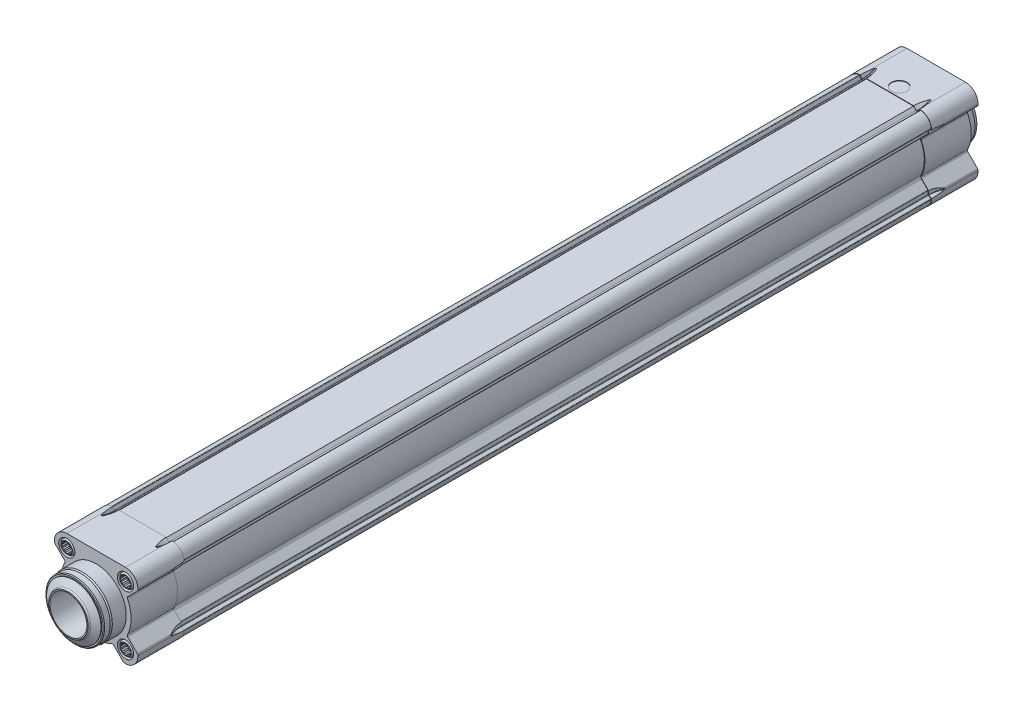
from build123d import *

# Parameters (mm, degrees)
BOSS_EXTRUDE1_DEPTH  = 30
SKETCH6_W            = 484
SKETCH6_H            = 5
BOSS_EXTRUDE2_START  = -30
BOSS_EXTRUDE2_DEPTH  = 30
BOSS_EXTRUDE3_DEPTH  = 484
SKETCH14_W           = 5
SKETCH14_H           = 0.3
SKETCH15_W           = 21.1
SKETCH15_H           = 5.25
LPATTERN1_COUNT      = 2
LPATTERN1_PITCH      = 38
LPATTERN1_COUNT_DIR2 = 2
LPATTERN1_PITCH_DIR2 = 38
LPATTERN2_COUNT      = 2
LPATTERN2_PITCH      = 38
LPATTERN2_COUNT_DIR2 = 2
LPATTERN2_PITCH_DIR2 = 38
CUT_EXTRUDE1_DEPTH   = 4
LPATTERN3_COUNT      = 2
LPATTERN3_PITCH      = 38
LPATTERN3_COUNT_DIR2 = 2
LPATTERN3_PITCH_DIR2 = 38
LPATTERN4_COUNT      = 2
LPATTERN4_PITCH      = 38
LPATTERN4_COUNT_DIR2 = 2
LPATTERN4_PITCH_DIR2 = 38
SKETCH25_W           = 21.1
SKETCH25_H           = 5.25
LPATTERN5_COUNT      = 2
LPATTERN5_PITCH      = 38
LPATTERN5_COUNT_DIR2 = 2
LPATTERN5_PITCH_DIR2 = 38
LPATTERN6_COUNT      = 2
LPATTERN6_PITCH      = 38
LPATTERN6_COUNT_DIR2 = 2
LPATTERN6_PITCH_DIR2 = 38
LPATTERN7_COUNT      = 2
LPATTERN7_PITCH      = 38
LPATTERN7_COUNT_DIR2 = 2
LPATTERN7_PITCH_DIR2 = 38
CUT_EXTRUDE2_DEPTH   = 4
LPATTERN8_COUNT      = 2
LPATTERN8_PITCH      = 38
LPATTERN8_COUNT_DIR2 = 2
LPATTERN8_PITCH_DIR2 = 38


with BuildPart() as part:
    # Sketch1 → Boss-Extrude1 (new body)
    with BuildSketch(Plane.XY.offset(-30)):
        with BuildLine():
            Line((-26.707106781, 17.514718626), (-20.456088466, 11.26370031))
            ThreePointArc((-20.456088466, 11.26370031), (-20.176183637, 10.717242468), (-20.268345554, 10.110225938))
            ThreePointArc((-20.268345554, 10.110225938), (-22.65, 0), (-20.268345554, -10.110225938))
            ThreePointArc((-20.268345554, -10.110225938), (-20.176183637, -10.717242468), (-20.456088466, -11.26370031))
            Line((-20.456088466, -11.26370031), (-26.707106781, -17.514718626))
            ThreePointArc((-26.707106781, -17.514718626), (-26.923879533, -17.839141975), (-27, -18.221825407))
            Line((-27, -18.221825407), (-27, -19))
            ThreePointArc((-27, -19), (-24.656854249, -24.656854249), (-19, -27))
            Line((-19, -27), (-18.221825407, -27))
            ThreePointArc((-18.221825407, -27), (-17.839141975, -26.923879533), (-17.514718626, -26.707106781))
            Line((-17.514718626, -26.707106781), (-11.26370031, -20.456088466))
            ThreePointArc((-11.26370031, -20.456088466), (-10.717242468, -20.176183637), (-10.110225938, -20.268345554))
            ThreePointArc((-10.110225938, -20.268345554), (0, -22.65), (10.110225938, -20.268345554))
            ThreePointArc((10.110225938, -20.268345554), (10.717242468, -20.176183637), (11.26370031, -20.456088466))
            Line((11.26370031, -20.456088466), (17.514718626, -26.707106781))
            ThreePointArc((17.514718626, -26.707106781), (17.839141975, -26.923879533), (18.221825407, -27))
            Line((18.221825407, -27), (19, -27))
            ThreePointArc((19, -27), (24.656854249, -24.656854249), (27, -19))
            Line((27, -19), (27, -18.221825407))
            ThreePointArc((27, -18.221825407), (26.923879533, -17.839141975), (26.707106781, -17.514718626))
            Line((26.707106781, -17.514718626), (20.456088466, -11.26370031))
            ThreePointArc((20.456088466, -11.26370031), (20.176183637, -10.717242468), (20.268345554, -10.110225938))
            ThreePointArc((20.268345554, -10.110225938), (22.65, 0), (20.268345554, 10.110225938))
            ThreePointArc((20.268345554, 10.110225938), (20.176183637, 10.717242468), (20.456088466, 11.26370031))
            Line((20.456088466, 11.26370031), (26.707106781, 17.514718626))
            ThreePointArc((26.707106781, 17.514718626), (26.923879533, 17.839141975), (27, 18.221825407))
            Line((27, 18.221825407), (27, 19))
            ThreePointArc((27, 19), (24.656854249, 24.656854249), (19, 27))
            Line((19, 27), (-19, 27))
            ThreePointArc((-19, 27), (-24.656854249, 24.656854249), (-27, 19))
            Line((-27, 19), (-27, 18.221825407))
            ThreePointArc((-27, 18.221825407), (-26.923879533, 17.839141975), (-26.707106781, 17.514718626))
        make_face()
    extrude(amount=BOSS_EXTRUDE1_DEPTH)

    # Sketch2 → Cut-Revolve1 (revolve, cut)
    with BuildSketch(Plane.XY.offset(-30)):
        with BuildLine():
            Line((-19.3, 33.75), (-19.3, 27))
            Line((-19.3, 27), (-18.203034489, 25.1))
            ThreePointArc((-18.203034489, 25.1), (-18.129829408, 25.026794919), (-18.029829408, 25))
            Line((-18.029829408, 25), (-17.328142174, 25))
            ThreePointArc((-17.328142174, 25), (-17.251605488, 25.015224093), (-17.186720818, 25.058578644))
            Line((-17.186720818, 25.058578644), (-15.245299462, 27))
            Line((-15.245299462, 27), (15.245299462, 27))
            Line((15.245299462, 27), (17.186720818, 25.058578644))
            ThreePointArc((17.186720818, 25.058578644), (17.251605488, 25.015224093), (17.328142174, 25))
            Line((17.328142174, 25), (18.029829408, 25))
            ThreePointArc((18.029829408, 25), (18.129829408, 25.026794919), (18.203034489, 25.1))
            Line((18.203034489, 25.1), (19.3, 27))
            Line((19.3, 27), (19.3, 33.75))
            Line((19.3, 33.75), (-19.3, 33.75))
        make_face()
    revolve(axis=Axis((-50, 45, -30), (1, 0, 0)), mode=Mode.SUBTRACT)

    # Sketch3 → Cut-Revolve2 (revolve, cut)
    with BuildSketch(Plane.XY.offset(-30)):
        with BuildLine():
            Line((-19.3, -33.75), (19.3, -33.75))
            Line((19.3, -33.75), (19.3, -27))
            Line((19.3, -27), (18.203034489, -25.1))
            ThreePointArc((18.203034489, -25.1), (18.129829408, -25.026794919), (18.029829408, -25))
            Line((18.029829408, -25), (5.737813172, -25))
            ThreePointArc((5.737813172, -25), (0, -25.65), (-5.737813172, -25))
            Line((-5.737813172, -25), (-18.029829408, -25))
            ThreePointArc((-18.029829408, -25), (-18.129829408, -25.026794919), (-18.203034489, -25.1))
            Line((-18.203034489, -25.1), (-19.3, -27))
            Line((-19.3, -27), (-19.3, -33.75))
        make_face()
    revolve(axis=Axis((50, -45, -30), (-1, 0, 0)), mode=Mode.SUBTRACT)

    # Sketch4 → Cut-Revolve3 (revolve, cut)
    with BuildSketch(Plane.XY.offset(-30)):
        with BuildLine():
            Line((25, -5.737813172), (25, -18.029829408))
            ThreePointArc((25, -18.029829408), (25.026794919, -18.129829408), (25.1, -18.203034489))
            Line((25.1, -18.203034489), (27, -19.3))
            Line((27, -19.3), (33.75, -19.3))
            Line((33.75, -19.3), (33.75, 19.3))
            Line((33.75, 19.3), (27, 19.3))
            Line((27, 19.3), (25.1, 18.203034489))
            ThreePointArc((25.1, 18.203034489), (25.026794919, 18.129829408), (25, 18.029829408))
            Line((25, 18.029829408), (25, 5.737813172))
            ThreePointArc((25, 5.737813172), (25.65, 0), (25, -5.737813172))
        make_face()
    revolve(axis=Axis((45, 50, -30), (0, -1, 0)), mode=Mode.SUBTRACT)

    # Sketch5 → Cut-Revolve4 (revolve, cut)
    with BuildSketch(Plane.XY.offset(-30)):
        with BuildLine():
            Line((-33.75, -19.3), (-27, -19.3))
            Line((-27, -19.3), (-25.1, -18.203034489))
            ThreePointArc((-25.1, -18.203034489), (-25.026794919, -18.129829408), (-25, -18.029829408))
            Line((-25, -18.029829408), (-25, -5.737813172))
            ThreePointArc((-25, -5.737813172), (-25.65, 0), (-25, 5.737813172))
            Line((-25, 5.737813172), (-25, 18.029829408))
            ThreePointArc((-25, 18.029829408), (-25.026794919, 18.129829408), (-25.1, 18.203034489))
            Line((-25.1, 18.203034489), (-27, 19.3))
            Line((-27, 19.3), (-33.75, 19.3))
            Line((-33.75, 19.3), (-33.75, -19.3))
        make_face()
    revolve(axis=Axis((-45, -50, -30), (0, 1, 0)), mode=Mode.SUBTRACT)

    # Sketch6 → Revolve1 (revolve)
    with BuildSketch(Plane(origin=(0, 0, 0), x_dir=(0, 0, -1), z_dir=(1, 0, 0))):
        with Locations((272, 2.5)):
            Rectangle(SKETCH6_W, SKETCH6_H)
    revolve(axis=Axis((0, 0, -514), (0, 0, 1)))

    # Sketch7 → Boss-Extrude2 (add)
    with BuildSketch(Plane.XY.offset(-514).offset(BOSS_EXTRUDE2_START)):
        with BuildLine():
            Line((-26.707106781, 17.514718626), (-20.456088466, 11.26370031))
            ThreePointArc((-20.456088466, 11.26370031), (-20.176183637, 10.717242468), (-20.268345554, 10.110225938))
            ThreePointArc((-20.268345554, 10.110225938), (-22.65, 0), (-20.268345554, -10.110225938))
            ThreePointArc((-20.268345554, -10.110225938), (-20.176183637, -10.717242468), (-20.456088466, -11.26370031))
            Line((-20.456088466, -11.26370031), (-26.707106781, -17.514718626))
            ThreePointArc((-26.707106781, -17.514718626), (-26.923879533, -17.839141975), (-27, -18.221825407))
            Line((-27, -18.221825407), (-27, -19))
            ThreePointArc((-27, -19), (-24.656854249, -24.656854249), (-19, -27))
            Line((-19, -27), (-18.221825407, -27))
            ThreePointArc((-18.221825407, -27), (-17.839141975, -26.923879533), (-17.514718626, -26.707106781))
            Line((-17.514718626, -26.707106781), (-11.26370031, -20.456088466))
            ThreePointArc((-11.26370031, -20.456088466), (-10.717242468, -20.176183637), (-10.110225938, -20.268345554))
            ThreePointArc((-10.110225938, -20.268345554), (0, -22.65), (10.110225938, -20.268345554))
            ThreePointArc((10.110225938, -20.268345554), (10.717242468, -20.176183637), (11.26370031, -20.456088466))
            Line((11.26370031, -20.456088466), (17.514718626, -26.707106781))
            ThreePointArc((17.514718626, -26.707106781), (17.839141975, -26.923879533), (18.221825407, -27))
            Line((18.221825407, -27), (19, -27))
            ThreePointArc((19, -27), (24.656854249, -24.656854249), (27, -19))
            Line((27, -19), (27, -18.221825407))
            ThreePointArc((27, -18.221825407), (26.923879533, -17.839141975), (26.707106781, -17.514718626))
            Line((26.707106781, -17.514718626), (20.456088466, -11.26370031))
            ThreePointArc((20.456088466, -11.26370031), (20.176183637, -10.717242468), (20.268345554, -10.110225938))
            ThreePointArc((20.268345554, -10.110225938), (22.65, 0), (20.268345554, 10.110225938))
            ThreePointArc((20.268345554, 10.110225938), (20.176183637, 10.717242468), (20.456088466, 11.26370031))
            Line((20.456088466, 11.26370031), (26.707106781, 17.514718626))
            ThreePointArc((26.707106781, 17.514718626), (26.923879533, 17.839141975), (27, 18.221825407))
            Line((27, 18.221825407), (27, 19))
            ThreePointArc((27, 19), (24.656854249, 24.656854249), (19, 27))
            Line((19, 27), (-19, 27))
            ThreePointArc((-19, 27), (-24.656854249, 24.656854249), (-27, 19))
            Line((-27, 19), (-27, 18.221825407))
            ThreePointArc((-27, 18.221825407), (-26.923879533, 17.839141975), (-26.707106781, 17.514718626))
        make_face()
    extrude(amount=BOSS_EXTRUDE2_DEPTH)

    # Sketch8 → Cut-Revolve5 (revolve, cut)
    with BuildSketch(Plane.XY.offset(-514)):
        with BuildLine():
            Line((-19.3, 33.75), (-19.3, 27))
            Line((-19.3, 27), (-18.203034489, 25.1))
            ThreePointArc((-18.203034489, 25.1), (-18.129829408, 25.026794919), (-18.029829408, 25))
            Line((-18.029829408, 25), (-17.328142174, 25))
            ThreePointArc((-17.328142174, 25), (-17.251605488, 25.015224093), (-17.186720818, 25.058578644))
            Line((-17.186720818, 25.058578644), (-15.245299462, 27))
            Line((-15.245299462, 27), (15.245299462, 27))
            Line((15.245299462, 27), (17.186720818, 25.058578644))
            ThreePointArc((17.186720818, 25.058578644), (17.251605488, 25.015224093), (17.328142174, 25))
            Line((17.328142174, 25), (18.029829408, 25))
            ThreePointArc((18.029829408, 25), (18.129829408, 25.026794919), (18.203034489, 25.1))
            Line((18.203034489, 25.1), (19.3, 27))
            Line((19.3, 27), (19.3, 33.75))
            Line((19.3, 33.75), (-19.3, 33.75))
        make_face()
    revolve(axis=Axis((-50, 45, -514), (1, 0, 0)), mode=Mode.SUBTRACT)

    # Sketch9 → Cut-Revolve6 (revolve, cut)
    with BuildSketch(Plane.XY.offset(-514)):
        with BuildLine():
            Line((-19.3, -27), (-19.3, -36))
            Line((-19.3, -36), (19.3, -36))
            Line((19.3, -36), (19.3, -27))
            Line((19.3, -27), (18.203034489, -25.1))
            ThreePointArc((18.203034489, -25.1), (18.129829408, -25.026794919), (18.029829408, -25))
            Line((18.029829408, -25), (5.737813172, -25))
            ThreePointArc((5.737813172, -25), (0, -25.65), (-5.737813172, -25))
            Line((-5.737813172, -25), (-18.029829408, -25))
            ThreePointArc((-18.029829408, -25), (-18.129829408, -25.026794919), (-18.203034489, -25.1))
            Line((-18.203034489, -25.1), (-19.3, -27))
        make_face()
    revolve(axis=Axis((50, -45, -514), (-1, 0, 0)), mode=Mode.SUBTRACT)

    # Sketch10 → Cut-Revolve7 (revolve, cut)
    with BuildSketch(Plane.XY.offset(-514)):
        with BuildLine():
            Line((25, -5.737813172), (25, -18.029829408))
            ThreePointArc((25, -18.029829408), (25.026794919, -18.129829408), (25.1, -18.203034489))
            Line((25.1, -18.203034489), (27, -19.3))
            Line((27, -19.3), (33.75, -19.3))
            Line((33.75, -19.3), (33.75, 19.3))
            Line((33.75, 19.3), (27, 19.3))
            Line((27, 19.3), (25.1, 18.203034489))
            ThreePointArc((25.1, 18.203034489), (25.026794919, 18.129829408), (25, 18.029829408))
            Line((25, 18.029829408), (25, 5.737813172))
            ThreePointArc((25, 5.737813172), (25.65, 0), (25, -5.737813172))
        make_face()
    revolve(axis=Axis((45, 50, -514), (0, -1, 0)), mode=Mode.SUBTRACT)

    # Sketch11 → Cut-Revolve8 (revolve, cut)
    with BuildSketch(Plane.XY.offset(-514)):
        with BuildLine():
            Line((-33.75, -19.3), (-27, -19.3))
            Line((-27, -19.3), (-25.1, -18.203034489))
            ThreePointArc((-25.1, -18.203034489), (-25.026794919, -18.129829408), (-25, -18.029829408))
            Line((-25, -18.029829408), (-25, -5.737813172))
            ThreePointArc((-25, -5.737813172), (-25.65, 0), (-25, 5.737813172))
            Line((-25, 5.737813172), (-25, 18.029829408))
            ThreePointArc((-25, 18.029829408), (-25.026794919, 18.129829408), (-25.1, 18.203034489))
            Line((-25.1, 18.203034489), (-27, 19.3))
            Line((-27, 19.3), (-33.75, 19.3))
            Line((-33.75, 19.3), (-33.75, -19.3))
        make_face()
    revolve(axis=Axis((-45, -50, -514), (0, 1, 0)), mode=Mode.SUBTRACT)

    # Sketch12 → Boss-Extrude3 (add)
    with BuildSketch(Plane.XY.offset(-30)):
        with BuildLine():
            Line((-19.54661595, -26.520821552), (-18.581966677, -24.85))
            ThreePointArc((-18.581966677, -24.85), (-18.435556515, -24.703589838), (-18.235556515, -24.65))
            Line((-18.235556515, -24.65), (-15.97685066, -24.65))
            ThreePointArc((-15.97685066, -24.65), (-15.823777287, -24.619551813), (-15.694007948, -24.532842712))
            Line((-15.694007948, -24.532842712), (-11.605563117, -20.444397882))
            ThreePointArc((-11.605563117, -20.444397882), (-10.638458744, -19.943336952), (-9.559424231, -20.091787087))
            ThreePointArc((-9.559424231, -20.091787087), (0, -22.25), (9.559424231, -20.091787087))
            ThreePointArc((9.559424231, -20.091787087), (10.638458744, -19.943336952), (11.605563117, -20.444397882))
            Line((11.605563117, -20.444397882), (15.694007948, -24.532842712))
            ThreePointArc((15.694007948, -24.532842712), (15.823777287, -24.619551813), (15.97685066, -24.65))
            Line((15.97685066, -24.65), (18.235556515, -24.65))
            ThreePointArc((18.235556515, -24.65), (18.435556515, -24.703589838), (18.581966677, -24.85))
            Line((18.581966677, -24.85), (19.54661595, -26.520821552))
            ThreePointArc((19.54661595, -26.520821552), (19.708934515, -26.67594165), (19.929252934, -26.719177696))
            ThreePointArc((19.929252934, -26.719177696), (24.553300859, -24.553300859), (26.719177696, -19.929252934))
            ThreePointArc((26.719177696, -19.929252934), (26.67594165, -19.708934515), (26.520821552, -19.54661595))
            Line((26.520821552, -19.54661595), (24.85, -18.581966677))
            ThreePointArc((24.85, -18.581966677), (24.703589838, -18.435556515), (24.65, -18.235556515))
            Line((24.65, -18.235556515), (24.65, -15.97685066))
            ThreePointArc((24.65, -15.97685066), (24.619551813, -15.823777287), (24.532842712, -15.694007948))
            Line((24.532842712, -15.694007948), (20.444397882, -11.605563117))
            ThreePointArc((20.444397882, -11.605563117), (19.943336952, -10.638458744), (20.091787087, -9.559424231))
            ThreePointArc((20.091787087, -9.559424231), (22.241097995, 0.629332977), (19.519086253, 10.680251488))
            Line((19.519086253, 10.680251488), (24.532842712, 15.694007948))
            ThreePointArc((24.532842712, 15.694007948), (24.619551813, 15.823777287), (24.65, 15.97685066))
            Line((24.65, 15.97685066), (24.65, 18.235556515))
            ThreePointArc((24.65, 18.235556515), (24.703589838, 18.435556515), (24.85, 18.581966677))
            Line((24.85, 18.581966677), (26.520821552, 19.54661595))
            ThreePointArc((26.520821552, 19.54661595), (26.67594165, 19.708934515), (26.719177696, 19.929252934))
            ThreePointArc((26.719177696, 19.929252934), (24.553300859, 24.553300859), (19.929252934, 26.719177696))
            ThreePointArc((19.929252934, 26.719177696), (19.708934515, 26.67594165), (19.54661595, 26.520821552))
            Line((19.54661595, 26.520821552), (18.581966677, 24.85))
            ThreePointArc((18.581966677, 24.85), (18.435556515, 24.703589838), (18.235556515, 24.65))
            Line((18.235556515, 24.65), (17.971320344, 24.65))
            ThreePointArc((17.971320344, 24.65), (17.397295195, 24.764180701), (16.910660172, 25.089339828))
            Line((16.910660172, 25.089339828), (15.25, 26.75))
            Line((15.25, 26.75), (-15.25, 26.75))
            Line((-15.25, 26.75), (-16.910660172, 25.089339828))
            ThreePointArc((-16.910660172, 25.089339828), (-17.397295195, 24.764180701), (-17.971320344, 24.65))
            Line((-17.971320344, 24.65), (-18.235556515, 24.65))
            ThreePointArc((-18.235556515, 24.65), (-18.435556515, 24.703589838), (-18.581966677, 24.85))
            Line((-18.581966677, 24.85), (-19.54661595, 26.520821552))
            ThreePointArc((-19.54661595, 26.520821552), (-19.708934515, 26.67594165), (-19.929252934, 26.719177696))
            ThreePointArc((-19.929252934, 26.719177696), (-24.553300859, 24.553300859), (-26.719177696, 19.929252934))
            ThreePointArc((-26.719177696, 19.929252934), (-26.67594165, 19.708934515), (-26.520821552, 19.54661595))
            Line((-26.520821552, 19.54661595), (-24.85, 18.581966677))
            ThreePointArc((-24.85, 18.581966677), (-24.703589838, 18.435556515), (-24.65, 18.235556515))
            Line((-24.65, 18.235556515), (-24.65, 15.97685066))
            ThreePointArc((-24.65, 15.97685066), (-24.619551813, 15.823777287), (-24.532842712, 15.694007948))
            Line((-24.532842712, 15.694007948), (-19.519086253, 10.680251488))
            ThreePointArc((-19.519086253, 10.680251488), (-22.241097995, 0.629332977), (-20.091787087, -9.559424231))
            ThreePointArc((-20.091787087, -9.559424231), (-19.943336952, -10.638458744), (-20.444397882, -11.605563117))
            Line((-20.444397882, -11.605563117), (-24.532842712, -15.694007948))
            ThreePointArc((-24.532842712, -15.694007948), (-24.619551813, -15.823777287), (-24.65, -15.97685066))
            Line((-24.65, -15.97685066), (-24.65, -18.235556515))
            ThreePointArc((-24.65, -18.235556515), (-24.703589838, -18.435556515), (-24.85, -18.581966677))
            Line((-24.85, -18.581966677), (-26.520821552, -19.54661595))
            ThreePointArc((-26.520821552, -19.54661595), (-26.67594165, -19.708934515), (-26.719177696, -19.929252934))
            ThreePointArc((-26.719177696, -19.929252934), (-24.553300859, -24.553300859), (-19.929252934, -26.719177696))
            ThreePointArc((-19.929252934, -26.719177696), (-19.708934515, -26.67594165), (-19.54661595, -26.520821552))
        make_face()
    extrude(amount=-BOSS_EXTRUDE3_DEPTH)

    # Sketch13 → Revolve2 (revolve)
    with BuildSketch(Plane(origin=(0, 0, 0), x_dir=(0, 0, -1), z_dir=(1, 0, 0))):
        with BuildLine():
            Line((-18, 0), (-18, 12.75))
            ThreePointArc((-18, 12.75), (-17.344877002, 12.927140321), (-16.868290464, 13.410286373))
            Line((-16.868290464, 13.410286373), (-14.5, 17.6))
            Line((-14.5, 17.6), (-14, 17.6))
            Line((-14, 17.6), (-14, 18.5))
            Line((-14, 18.5), (-13.5, 19))
            Line((-13.5, 19), (-9.866025404, 19))
            Line((-9.866025404, 19), (-9, 19.5))
            Line((-9, 19.5), (0, 19.5))
            Line((0, 19.5), (0, 0))
            Line((0, 0), (-18, 0))
        make_face()
    revolve(axis=Axis((0, 0, 0), (0, 0, 1)))

    # Sketch14 → Cut-Revolve9 (revolve, cut)
    with BuildSketch(Plane.XY.offset(-520)):
        with Locations((2.5, 26.85)):
            Rectangle(SKETCH14_W, SKETCH14_H)
    revolve(axis=Axis((0, 26.7, -520), (0, 1, 0)), mode=Mode.SUBTRACT)

    # Sketch15 → Cut-Revolve10 (revolve, cut)
    with BuildSketch(Plane(origin=(19, 0, 0), x_dir=(0, 0, -1), z_dir=(1, 0, 0))):
        with Locations((10.55, 21.625)):
            Rectangle(SKETCH15_W, SKETCH15_H)
    cut_revolve10 = revolve(axis=Axis((19, 19, -21.1), (0, 0, 1)), mode=Mode.SUBTRACT)

    # LPattern1: Cut-Revolve10 2 × 2
    with Locations(*[(-i * LPATTERN1_PITCH, -j * LPATTERN1_PITCH_DIR2, 0) for i in range(LPATTERN1_COUNT) for j in range(LPATTERN1_COUNT_DIR2) if (i, j) != (0, 0)]):
        add(cut_revolve10, mode=Mode.SUBTRACT)

    # Sketch17 → Revolve3 (revolve)
    with BuildSketch(Plane(origin=(19, 0, 0), x_dir=(0, 0, -1), z_dir=(1, 0, 0))):
        Polygon((0, 19), (0, 22.660900369), (1, 23.5), (21.1, 23.5), (21.1, 19), align=None)
    revolve3 = revolve(axis=Axis((19, 19, -21.1), (0, 0, 1)))

    # LPattern2: Revolve3 2 × 2
    with Locations(*[(-i * LPATTERN2_PITCH, -j * LPATTERN2_PITCH_DIR2, 0) for i in range(LPATTERN2_COUNT) for j in range(LPATTERN2_COUNT_DIR2) if (i, j) != (0, 0)]):
        add(revolve3)

    # Sketch19 → Cut-Revolve11 (revolve, cut)
    with BuildSketch(Plane(origin=(19, 0, 0), x_dir=(0, 0, -1), z_dir=(1, 0, 0))):
        Polygon((0, 19), (0, 22.5), (0.288675135, 22), (5.5, 22), (6.0415, 21.4585), (18.7, 21.4585), (20.119415637, 19), align=None)
    cut_revolve11 = revolve(axis=Axis((19, 19, -20.119415637), (0, 0, 1)), mode=Mode.SUBTRACT)

    # Sketch20 → Cut-Extrude1 (cut, symmetric)
    with BuildSketch(Plane.XY):
        Polygon((15.535898385, 19), (16, 18.196152423), (16, 17.267949192), (16.803847577, 16.803847577), (17.267949192, 16), (18.196152423, 16), (19, 15.535898385), (19.803847577, 16), (20.732050808, 16), (21.196152423, 16.803847577), (22, 17.267949192), (22, 18.196152423), (22.464101615, 19), (22, 19.803847577), (22, 20.732050808), (21.196152423, 21.196152423), (20.732050808, 22), (19.803847577, 22), (19, 22.464101615), (18.196152423, 22), (17.267949192, 22), (16.803847577, 21.196152423), (16, 20.732050808), (16, 19.803847577), align=None)
    cut_extrude1 = extrude(amount=CUT_EXTRUDE1_DEPTH, both=True, mode=Mode.SUBTRACT)

    # LPattern3: Cut-Revolve11 2 × 2
    with Locations(*[(-i * LPATTERN3_PITCH, -j * LPATTERN3_PITCH_DIR2, 0) for i in range(LPATTERN3_COUNT) for j in range(LPATTERN3_COUNT_DIR2) if (i, j) != (0, 0)]):
        add(cut_revolve11, mode=Mode.SUBTRACT)

    # LPattern4: Cut-Extrude1 2 × 2
    with Locations(*[(-i * LPATTERN4_PITCH, -j * LPATTERN4_PITCH_DIR2, 0) for i in range(LPATTERN4_COUNT) for j in range(LPATTERN4_COUNT_DIR2) if (i, j) != (0, 0)]):
        add(cut_extrude1, mode=Mode.SUBTRACT)

    # Sketch23 → Revolve4 (revolve)
    with BuildSketch(Plane(origin=(0, 0, 0), x_dir=(0, 0, -1), z_dir=(1, 0, 0))):
        Polygon((544, 0), (544, 20), (549, 20), (551, 19.272059531), (551, 0), align=None)
    revolve(axis=Axis((0, 0, -551), (0, 0, 1)))

    # Sketch24 → Cut-Revolve12 (revolve, cut)
    with BuildSketch(Plane(origin=(0, 0, 0), x_dir=(0, 0, -1), z_dir=(1, 0, 0))):
        Polygon((514, 0), (514, 5), (540.8, 5), (540.8, 16.5), (550, 16.5), (551, 16.863970234), (551, 0), align=None)
    revolve(axis=Axis((0, 0, -551), (0, 0, 1)), mode=Mode.SUBTRACT)

    # Sketch25 → Cut-Revolve13 (revolve, cut)
    with BuildSketch(Plane(origin=(19, 0, 0), x_dir=(0, 0, -1), z_dir=(1, 0, 0))):
        with Locations((533.45, 21.625)):
            Rectangle(SKETCH25_W, SKETCH25_H)
    cut_revolve13 = revolve(axis=Axis((19, 19, -544), (0, 0, 1)), mode=Mode.SUBTRACT)

    # LPattern5: Cut-Revolve13 2 × 2
    with Locations(*[(-i * LPATTERN5_PITCH, -j * LPATTERN5_PITCH_DIR2, 0) for i in range(LPATTERN5_COUNT) for j in range(LPATTERN5_COUNT_DIR2) if (i, j) != (0, 0)]):
        add(cut_revolve13, mode=Mode.SUBTRACT)

    # Sketch27 → Revolve5 (revolve)
    with BuildSketch(Plane(origin=(19, 0, 0), x_dir=(0, 0, -1), z_dir=(1, 0, 0))):
        Polygon((522.9, 19), (522.9, 23.5), (543, 23.5), (544, 22.660900369), (544, 19), align=None)
    revolve5 = revolve(axis=Axis((19, 19, -544), (0, 0, 1)))

    # LPattern6: Revolve5 2 × 2
    with Locations(*[(-i * LPATTERN6_PITCH, -j * LPATTERN6_PITCH_DIR2, 0) for i in range(LPATTERN6_COUNT) for j in range(LPATTERN6_COUNT_DIR2) if (i, j) != (0, 0)]):
        add(revolve5)

    # Sketch29 → Cut-Revolve14 (revolve, cut)
    with BuildSketch(Plane(origin=(19, 0, 0), x_dir=(0, 0, -1), z_dir=(1, 0, 0))):
        Polygon((523.880584363, 19), (525.3, 21.4585), (537.9585, 21.4585), (538.5, 22), (543.711324865, 22), (544, 22.5), (544, 19), align=None)
    cut_revolve14 = revolve(axis=Axis((19, 19, -544), (0, 0, 1)), mode=Mode.SUBTRACT)

    # LPattern7: Cut-Revolve14 2 × 2
    with Locations(*[(-i * LPATTERN7_PITCH, -j * LPATTERN7_PITCH_DIR2, 0) for i in range(LPATTERN7_COUNT) for j in range(LPATTERN7_COUNT_DIR2) if (i, j) != (0, 0)]):
        add(cut_revolve14, mode=Mode.SUBTRACT)

    # Sketch31 → Cut-Extrude2 (cut, symmetric)
    with BuildSketch(Plane.XY.offset(-544)):
        Polygon((15.535898385, 19), (16, 18.196152423), (16, 17.267949192), (16.803847577, 16.803847577), (17.267949192, 16), (18.196152423, 16), (19, 15.535898385), (19.803847577, 16), (20.732050808, 16), (21.196152423, 16.803847577), (22, 17.267949192), (22, 18.196152423), (22.464101615, 19), (22, 19.803847577), (22, 20.732050808), (21.196152423, 21.196152423), (20.732050808, 22), (19.803847577, 22), (19, 22.464101615), (18.196152423, 22), (17.267949192, 22), (16.803847577, 21.196152423), (16, 20.732050808), (16, 19.803847577), align=None)
    cut_extrude2 = extrude(amount=CUT_EXTRUDE2_DEPTH, both=True, mode=Mode.SUBTRACT)

    # LPattern8: Cut-Extrude2 2 × 2
    with Locations(*[(-i * LPATTERN8_PITCH, -j * LPATTERN8_PITCH_DIR2, 0) for i in range(LPATTERN8_COUNT) for j in range(LPATTERN8_COUNT_DIR2) if (i, j) != (0, 0)]):
        add(cut_extrude2, mode=Mode.SUBTRACT)

    # Sketch33 → Cut-Revolve15 (revolve, cut)
    with BuildSketch(Plane(origin=(0, 0, 0), x_dir=(0, 0, -1), z_dir=(1, 0, 0))):
        Polygon((-18, 0), (-18, 12), (100.666666667, 12), (100.666666667, 20), (514, 20), (514, 0), align=None)
    revolve(axis=Axis((0, 0, -514), (0, 0, 1)), mode=Mode.SUBTRACT)


solid = part.part
